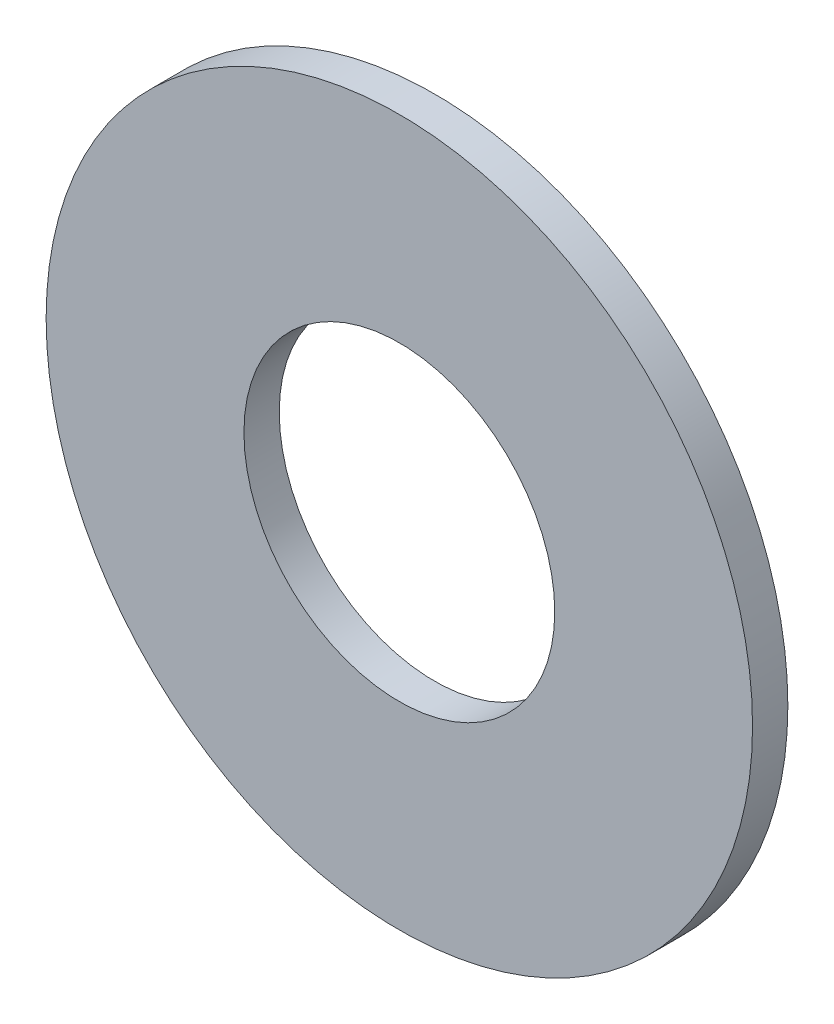
from build123d import *

# Parameters (mm, degrees)
SKETCH1_R      = 2.5
SKETCH1_R_2    = 1.1
EXTRUDE1_DEPTH = 0.25


with BuildPart() as part:
    # Sketch1 → Extrude1 (new body)
    with BuildSketch(Plane.XY):
        Circle(SKETCH1_R)
        Circle(SKETCH1_R_2, mode=Mode.SUBTRACT)
    extrude(amount=-EXTRUDE1_DEPTH)


solid = part.part
